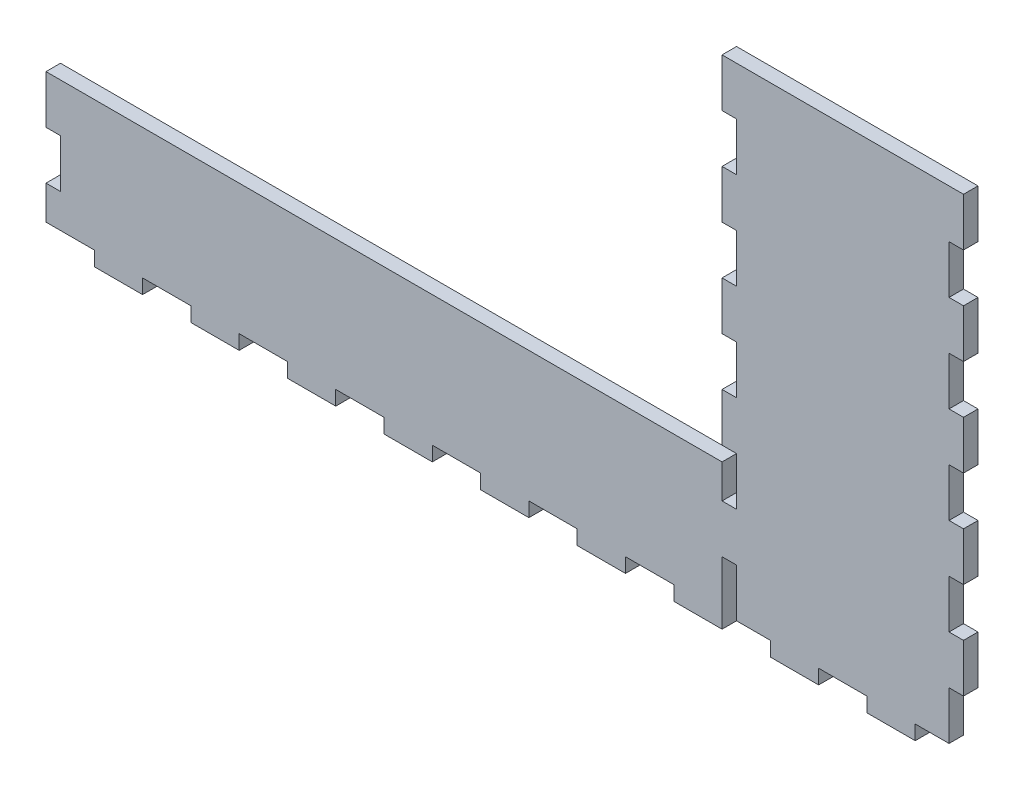
from build123d import *

# Parameters (mm, degrees)
BOSS_EXTRUDE1_DEPTH = 6
SKETCH2_W           = 20
SKETCH2_H           = 6
CUT_EXTRUDE1_DEPTH  = 10
LPATTERN1_COUNT     = 10
LPATTERN1_PITCH     = 40
SKETCH3_W           = 6
SKETCH3_H           = 20
CUT_EXTRUDE2_DEPTH  = 10
SKETCH4_W           = 6
SKETCH4_H           = 20
CUT_EXTRUDE3_DEPTH  = 10
LPATTERN2_COUNT     = 5
LPATTERN2_PITCH     = 40
SKETCH5_W           = 6
SKETCH5_H           = 20
CUT_EXTRUDE4_DEPTH  = 10
LPATTERN3_COUNT     = 5
LPATTERN3_PITCH     = 40


with BuildPart() as part:
    # Sketch1 → Boss-Extrude1 (new body)
    with BuildSketch(Plane.XY):
        Polygon((-220.231213873, -93.901734104), (59.768786127, -93.901734104), (59.768786127, 52.098265896), (159.768786127, 52.098265896), (159.768786127, -153.901734104), (59.768786127, -153.901734104), (-220.231213873, -153.901734104), align=None)
    extrude(amount=BOSS_EXTRUDE1_DEPTH)

    # Sketch2 → Cut-Extrude1 (cut)
    with BuildSketch(Plane.XY.offset(6)):
        with Locations((-210.231213873, -150.901734104)):
            Rectangle(SKETCH2_W, SKETCH2_H)
    cut_extrude1 = extrude(amount=-CUT_EXTRUDE1_DEPTH, mode=Mode.SUBTRACT)

    # LPattern1: Cut-Extrude1 ×10
    with Locations(*[(i * LPATTERN1_PITCH, 0, 0) for i in range(1, LPATTERN1_COUNT)]):
        add(cut_extrude1, mode=Mode.SUBTRACT)

    # Sketch3 → Cut-Extrude2 (cut)
    with BuildSketch(Plane.XY.offset(6)):
        with Locations((-217.231213873, -123.901734104)):
            Rectangle(SKETCH3_W, SKETCH3_H)
    extrude(amount=-CUT_EXTRUDE2_DEPTH, mode=Mode.SUBTRACT)

    # Sketch4 → Cut-Extrude3 (cut)
    with BuildSketch(Plane.XY.offset(6)):
        with Locations((156.768786127, 22.098265896)):
            Rectangle(SKETCH4_W, SKETCH4_H)
    cut_extrude3 = extrude(amount=-CUT_EXTRUDE3_DEPTH, mode=Mode.SUBTRACT)

    # LPattern2: Cut-Extrude3 ×5
    with Locations(*[(0, -i * LPATTERN2_PITCH, 0) for i in range(1, LPATTERN2_COUNT)]):
        add(cut_extrude3, mode=Mode.SUBTRACT)

    # Sketch5 → Cut-Extrude4 (cut)
    with BuildSketch(Plane.XY.offset(6)):
        with Locations((62.768786127, 22.098265896)):
            Rectangle(SKETCH5_W, SKETCH5_H)
    cut_extrude4 = extrude(amount=-CUT_EXTRUDE4_DEPTH, mode=Mode.SUBTRACT)

    # LPattern3: Cut-Extrude4 ×5
    with Locations(*[(0, -i * LPATTERN3_PITCH, 0) for i in range(1, LPATTERN3_COUNT)]):
        add(cut_extrude4, mode=Mode.SUBTRACT)


solid = part.part
